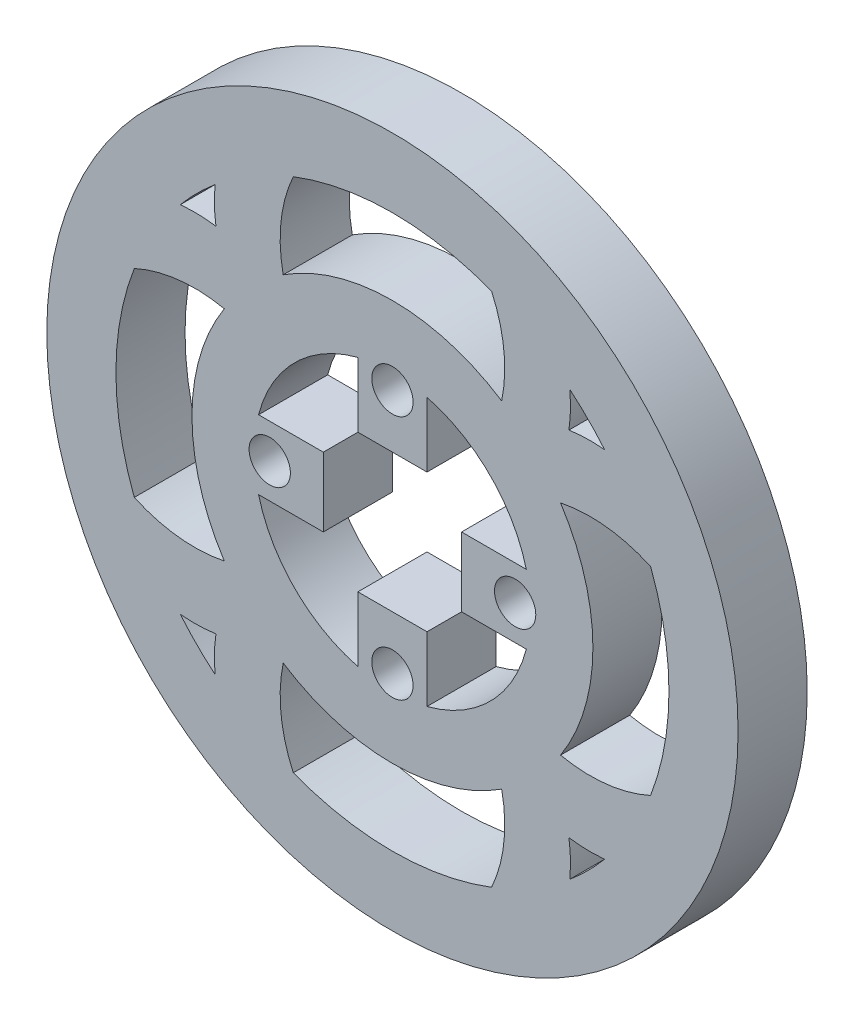
from build123d import *

# Parameters (mm, degrees)
SKETCH6_R                    = 29
SKETCH6_R_2                  = 20
INNER_RING_DEPTH             = 10
MOTOR_CONNECTOR_CUT_DEPTH    = 10
SKETCH9_R                    = 50
SKETCH9_R_2                  = 29
OUTSIDE_RING_EXTRUSION_DEPTH = 10
SKETCH12_R                   = 45
SKETCH12_R_2                 = 27.5
CUT_EXTRUDE6_DEPTH           = 55
SKETCH8_R                    = 2.987
MOTOR_CONNECTOR_HOLES_DEPTH  = 10
SKETCH10_R                   = 27.404299948
PATTERN_DEPTH                = 10
SKETCH13_R                   = 45
SKETCH13_R_2                 = 40
BOSS_EXTRUDE1_DEPTH          = 10


with BuildPart() as part:
    # Sketch6 → Inner Ring (new body)
    with BuildSketch(Plane.XY):
        Circle(SKETCH6_R)
        Circle(SKETCH6_R_2, mode=Mode.SUBTRACT)
    extrude(amount=-INNER_RING_DEPTH)

    # Sketch7 → Motor Connector Cut (add)
    with BuildSketch(Plane.XY):
        with BuildLine():
            ThreePointArc((20, 0), (19.840593925, 2.52008585), (19.364916731, 5))
            Line((19.364916731, 5), (9.999996731, 5))
            Line((9.999996731, 5), (9.999996731, -5))
            Line((9.999996731, -5), (19.364916731, -5))
            ThreePointArc((19.364916731, -5), (19.840593925, -2.52008585), (20, 0))
        make_face()
        with BuildLine():
            ThreePointArc((5, 19.364916731), (0, 20), (-5, 19.364916731))
            Line((-5, 19.364916731), (-5, 9.999996731))
            Line((-5, 9.999996731), (5, 9.999996731))
            Line((5, 9.999996731), (5, 19.364916731))
        make_face()
        with BuildLine():
            Line((-9.999996731, -5), (-9.999996731, 5))
            Line((-9.999996731, 5), (-19.364916731, 5))
            ThreePointArc((-19.364916731, 5), (-20, 0), (-19.364916731, -5))
            Line((-19.364916731, -5), (-9.999996731, -5))
        make_face()
        with BuildLine():
            Line((-5, -9.999996731), (-5, -19.364916731))
            ThreePointArc((-5, -19.364916731), (0, -20), (5, -19.364916731))
            Line((5, -19.364916731), (5, -9.999996731))
            Line((5, -9.999996731), (-5, -9.999996731))
        make_face()
    extrude(amount=-MOTOR_CONNECTOR_CUT_DEPTH)

    # Sketch9 → Outside Ring Extrusion (add)
    with BuildSketch(Plane.XY):
        Circle(SKETCH9_R)
        Circle(SKETCH9_R_2, mode=Mode.SUBTRACT)
    extrude(amount=-OUTSIDE_RING_EXTRUSION_DEPTH)

    # Sketch12 → Cut-Extrude6 (cut)
    with BuildSketch(Plane.XY):
        Circle(SKETCH12_R)
        Circle(SKETCH12_R_2, mode=Mode.SUBTRACT)
    extrude(amount=-CUT_EXTRUDE6_DEPTH, mode=Mode.SUBTRACT)

    # Sketch8 → Motor Connector Holes (cut)
    with BuildSketch(Plane.XY):
        with Locations((0, 17.75)):
            Circle(SKETCH8_R)
        with Locations((17.75, 0)):
            Circle(SKETCH8_R)
        with Locations((0, -17.75)):
            Circle(SKETCH8_R)
        with Locations((-17.75, 0)):
            Circle(SKETCH8_R)
    extrude(amount=-MOTOR_CONNECTOR_HOLES_DEPTH, mode=Mode.SUBTRACT)

    # Sketch10 → Pattern (add)
    with BuildSketch(Plane.XY):
        with BuildLine():
            ThreePointArc((24.317625284, 15.800414568), (34.856582319, 15.291767932), (43.817916626, 9.721954269))
            ThreePointArc((43.817916626, 9.721954269), (41.607188912, 16.793289988), (38.263814419, 23.404867172))
            ThreePointArc((38.263814419, 23.404867172), (32.064348025, 25.470287935), (25.530148518, 25.530148518))
            ThreePointArc((25.530148518, 25.530148518), (25.475284033, 32.034279432), (23.432821057, 38.209639668))
            ThreePointArc((23.432821057, 38.209639668), (20.212556871, 40.002288656), (16.856128399, 41.524812789))
            ThreePointArc((16.856128399, 41.524812789), (13.384732217, 42.767397097), (9.823095744, 43.720997037))
            ThreePointArc((9.823095744, 43.720997037), (15.312499865, 34.789679765), (15.800414568, 24.317625284))
            ThreePointArc((15.800414568, 24.317625284), (0, 29), (-15.800414568, 24.317625284))
            ThreePointArc((-15.800414568, 24.317625284), (-15.312499865, 34.789679765), (-9.823095744, 43.720997037))
            ThreePointArc((-9.823095744, 43.720997037), (-16.854754984, 41.52536899), (-23.432821057, 38.209639668))
            ThreePointArc((-23.432821057, 38.209639668), (-25.475284033, 32.034279432), (-25.530148518, 25.530148518))
            ThreePointArc((-25.530148518, 25.530148518), (-32.064348025, 25.470287935), (-38.263814419, 23.404867172))
            ThreePointArc((-38.263814419, 23.404867172), (-41.607188912, 16.793289988), (-43.817916626, 9.721954269))
            ThreePointArc((-43.817916626, 9.721954269), (-34.856582319, 15.291767932), (-24.317625284, 15.800414568))
            ThreePointArc((-24.317625284, 15.800414568), (-29, 0), (-24.317625284, -15.800414568))
            ThreePointArc((-24.317625284, -15.800414568), (-34.894848495, -15.279799844), (-43.87309253, -9.663767027))
            ThreePointArc((-43.87309253, -9.663767027), (-41.716263612, -16.713446711), (-38.435015504, -23.315212041))
            ThreePointArc((-38.435015504, -23.315212041), (-32.159621016, -25.454161245), (-25.530148518, -25.530148518))
            ThreePointArc((-25.530148518, -25.530148518), (-25.448803812, -32.190695038), (-23.285614603, -38.490703716))
            ThreePointArc((-23.285614603, -38.490703716), (-16.649731385, -41.799208281), (-9.559859326, -43.970581744))
            ThreePointArc((-9.559859326, -43.970581744), (-15.258354287, -34.962784804), (-15.800414568, -24.317625284))
            ThreePointArc((-15.800414568, -24.317625284), (0, -29), (15.800414568, -24.317625284))
            ThreePointArc((15.800414568, -24.317625284), (15.258354287, -34.962784804), (9.559859326, -43.970581744))
            ThreePointArc((9.559859326, -43.970581744), (16.649731385, -41.799208281), (23.285614603, -38.490703716))
            ThreePointArc((23.285614603, -38.490703716), (25.448803812, -32.190695038), (25.530148518, -25.530148518))
            ThreePointArc((25.530148518, -25.530148518), (32.159621016, -25.454161245), (38.435015504, -23.315212041))
            ThreePointArc((38.435015504, -23.315212041), (41.716263612, -16.713446711), (43.87309253, -9.663767027))
            ThreePointArc((43.87309253, -9.663767027), (34.894848495, -15.279799844), (24.317625284, -15.800414568))
            ThreePointArc((24.317625284, -15.800414568), (29, 0), (24.317625284, 15.800414568))
        make_face()
        with Locations((-0.095700052, 0)):
            Circle(SKETCH10_R, mode=Mode.SUBTRACT)
    extrude(amount=-PATTERN_DEPTH)

    # Sketch13 → Boss-Extrude1 (add)
    with BuildSketch(Plane(origin=(0, 0, -10), x_dir=(-1, 0, 0), z_dir=(0, 0, -1))):
        Circle(SKETCH13_R)
        Circle(SKETCH13_R_2, mode=Mode.SUBTRACT)
    extrude(amount=-BOSS_EXTRUDE1_DEPTH)


solid = part.part
